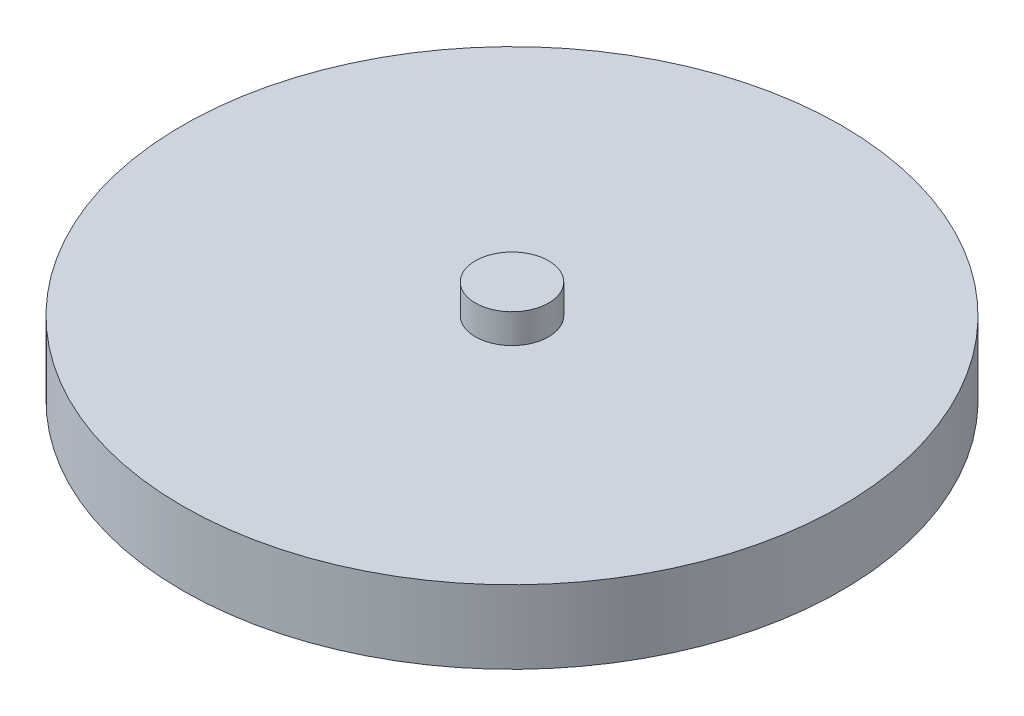
from build123d import *

# Parameters (mm, degrees)
SKETCH1_R           = 22.5
BOSS_EXTRUDE1_DEPTH = 5
SKETCH2_R           = 2.5
BOSS_EXTRUDE2_DEPTH = 2


with BuildPart() as part:
    # Sketch1 → Boss-Extrude1 (new body)
    with BuildSketch(Plane(origin=(0, 0, 0), x_dir=(1, 0, 0), z_dir=(0, 1, 0))):
        Circle(SKETCH1_R)
    extrude(amount=BOSS_EXTRUDE1_DEPTH)

    # Sketch2 → Boss-Extrude2 (add)
    with BuildSketch(Plane(origin=(0, 5, 0), x_dir=(1, 0, 0), z_dir=(0, 1, 0))):
        Circle(SKETCH2_R)
    extrude(amount=BOSS_EXTRUDE2_DEPTH)


solid = part.part
